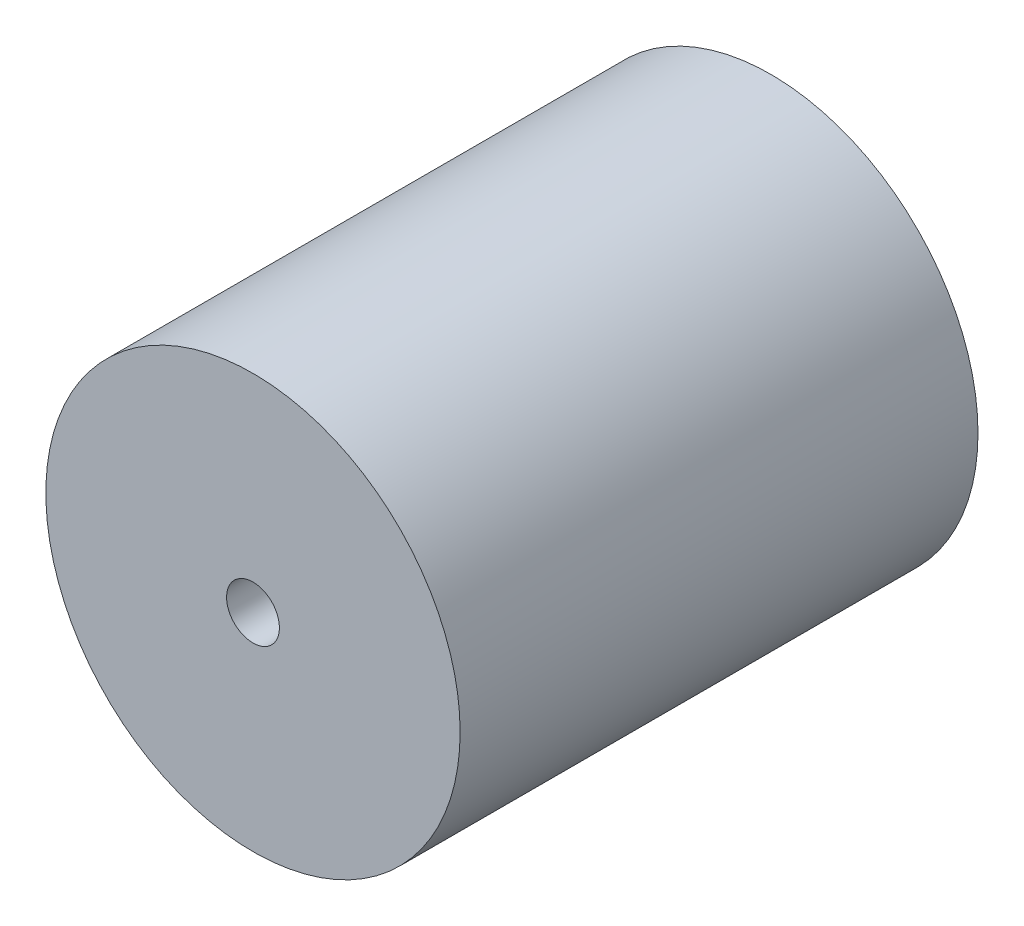
from build123d import *

# Parameters (mm, degrees)
SKIZZE1_R                       = 40
AUFSATZ_LINEAR_AUSTRAGEN1_DEPTH = 100
SKIZZE2_R                       = 5.1
SCHNITT_LINEAR_AUSTRAGEN1_DEPTH = 25


with BuildPart() as part:
    # Skizze1 → Aufsatz-Linear austragen1 (new body)
    with BuildSketch(Plane.XY):
        Circle(SKIZZE1_R)
    extrude(amount=AUFSATZ_LINEAR_AUSTRAGEN1_DEPTH)

    # Skizze2 → Schnitt-Linear austragen1 (cut)
    with BuildSketch(Plane.XY.offset(100)):
        Circle(SKIZZE2_R)
    extrude(amount=-SCHNITT_LINEAR_AUSTRAGEN1_DEPTH, mode=Mode.SUBTRACT)


solid = part.part
